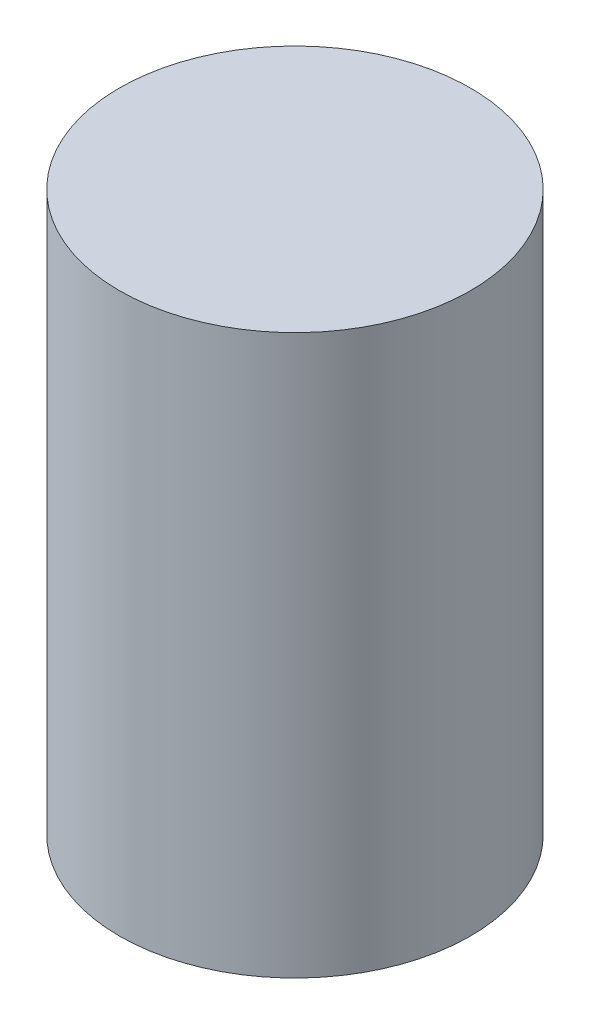
from build123d import *

# Parameters (mm, degrees)
SKETCH1_R      = 797.687
EXTRUDE1_DEPTH = 1270


with BuildPart() as part:
    # Sketch1 → Extrude1 (new body, symmetric)
    with BuildSketch(Plane(origin=(0, 0, 0), x_dir=(1, 0, 0), z_dir=(0, 1, 0))):
        with Locations(Location((0, 0, 0), (0, 0, 270))):  # turned: the seam where the file's is
            Circle(SKETCH1_R)
    extrude(amount=EXTRUDE1_DEPTH, both=True)


solid = part.part
